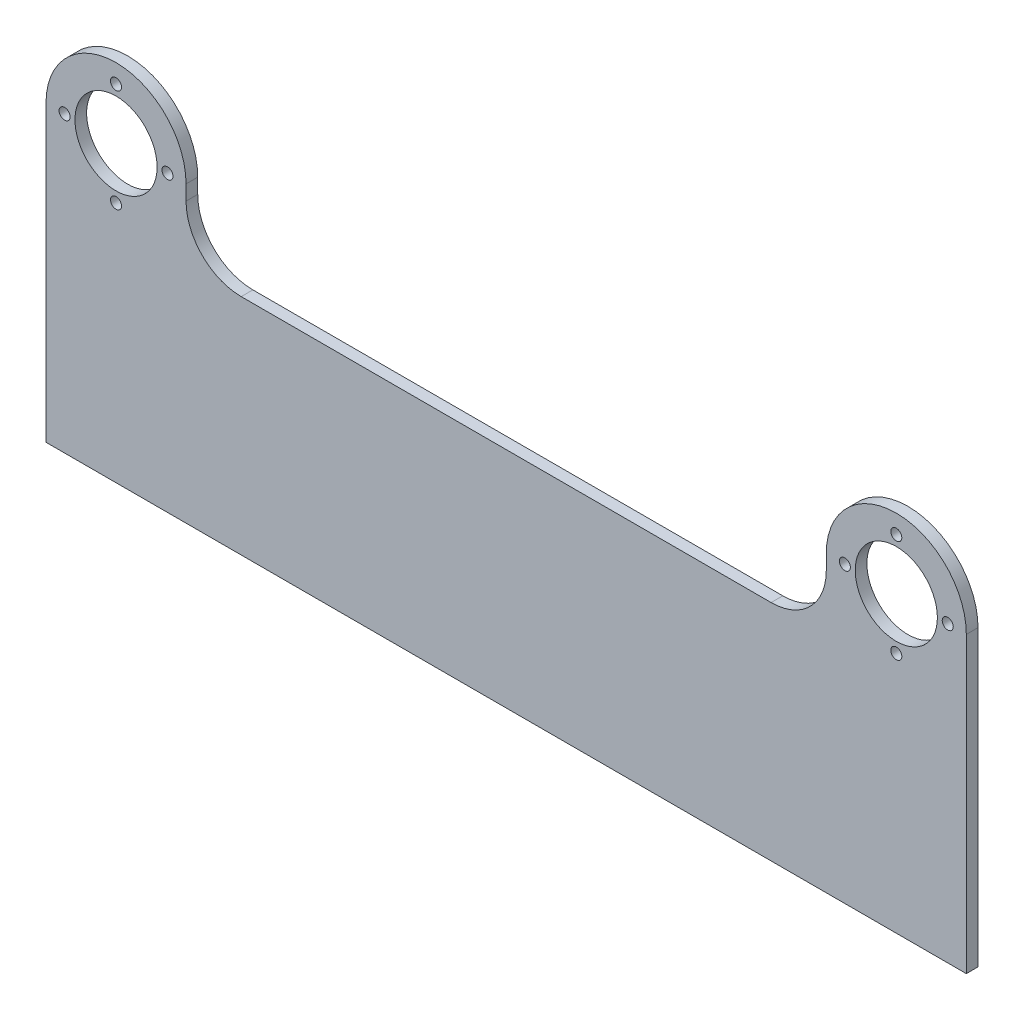
from build123d import *

# Parameters (mm, degrees)
SKETCH1_R           = 11.176
SKETCH1_R_2         = 1.5
BOSS_EXTRUDE1_DEPTH = 3.175


with BuildPart() as part:
    # Sketch1 → Boss-Extrude1 (new body)
    with BuildSketch(Plane.XY):
        with BuildLine():
            Line((-19.05, -19.05), (-19.05, 0))
            ThreePointArc((-19.05, 0), (0, 19.05), (19.05, 0))
            Line((19.05, 0), (19.05, -4.05))
            ThreePointArc((19.05, -4.05), (23.443398282, -14.656601718), (34.05, -19.05))
            Line((34.05, -19.05), (178.2, -19.05))
            ThreePointArc((178.2, -19.05), (188.806601718, -14.656601718), (193.2, -4.05))
            Line((193.2, -4.05), (193.2, 0))
            ThreePointArc((193.2, 0), (212.25, 19.05), (231.3, 0))
            Line((231.3, 0), (231.3, -19.05))
            Line((231.3, -19.05), (231.3, -79.925453532))
            Line((231.3, -79.925453532), (-19.05, -79.925453532))
            Line((-19.05, -79.925453532), (-19.05, -19.05))
        make_face()
        Circle(SKETCH1_R, mode=Mode.SUBTRACT)
        with Locations((212.25, 0)):
            Circle(SKETCH1_R, mode=Mode.SUBTRACT)
        with Locations((0, 13.9954)):
            Circle(SKETCH1_R_2, mode=Mode.SUBTRACT)
        with Locations((212.25, 13.9954)):
            Circle(SKETCH1_R_2, mode=Mode.SUBTRACT)
        with Locations((13.9954, 0)):
            Circle(SKETCH1_R_2, mode=Mode.SUBTRACT)
        with Locations((0, -13.9954)):
            Circle(SKETCH1_R_2, mode=Mode.SUBTRACT)
        with Locations((-13.9954, 0)):
            Circle(SKETCH1_R_2, mode=Mode.SUBTRACT)
        with Locations((198.2546, 0)):
            Circle(SKETCH1_R_2, mode=Mode.SUBTRACT)
        with Locations((212.25, -13.9954)):
            Circle(SKETCH1_R_2, mode=Mode.SUBTRACT)
        with Locations((226.2454, 0)):
            Circle(SKETCH1_R_2, mode=Mode.SUBTRACT)
    extrude(amount=BOSS_EXTRUDE1_DEPTH)


solid = part.part
